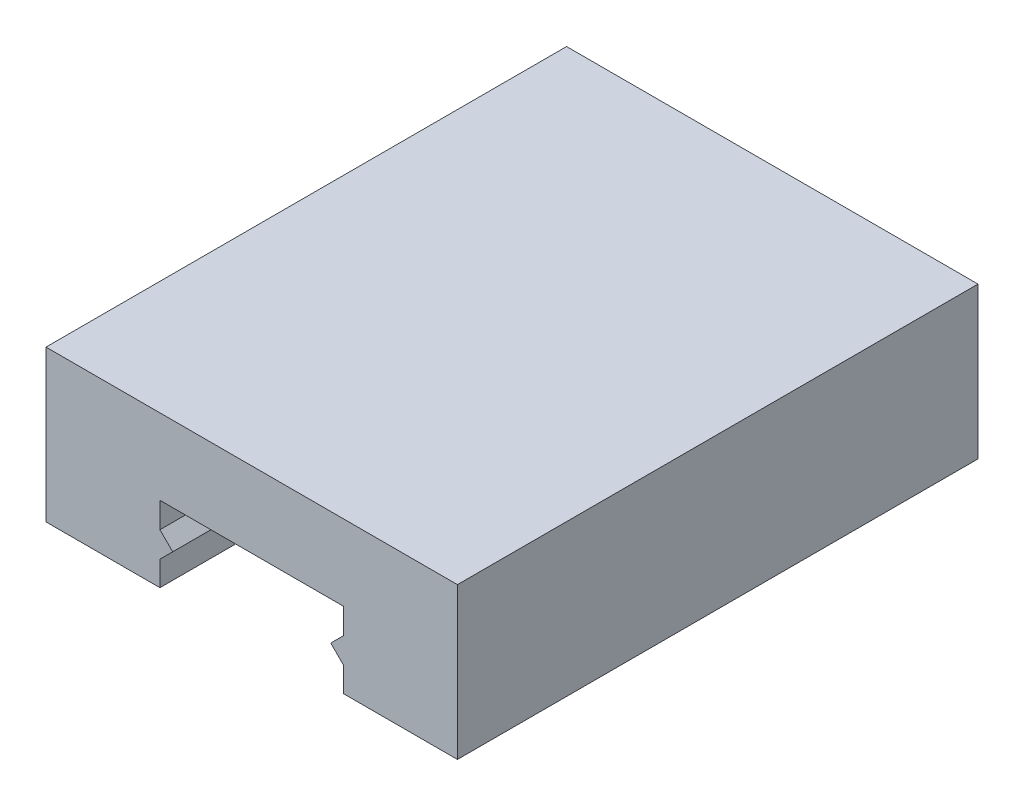
from build123d import *

# Parameters (mm, degrees)
BOSS_EXTRUDE1_DEPTH = 34.036


with BuildPart() as part:
    # Sketch1 → Boss-Extrude1 (new body)
    with BuildSketch(Plane.XY):
        Polygon((-6, 1.666666667), (-5.166666667, 2.5), (-6, 3.333333333), (-6, 5), (6, 5), (6, 3.333333333), (5.166666667, 2.5), (6, 1.666666667), (6, 0.05), (13.45, 0.05), (13.45, 9.95), (-13.45, 9.95), (-13.45, 0.05), (-6, 0.05), align=None)
    extrude(amount=BOSS_EXTRUDE1_DEPTH)


solid = part.part
